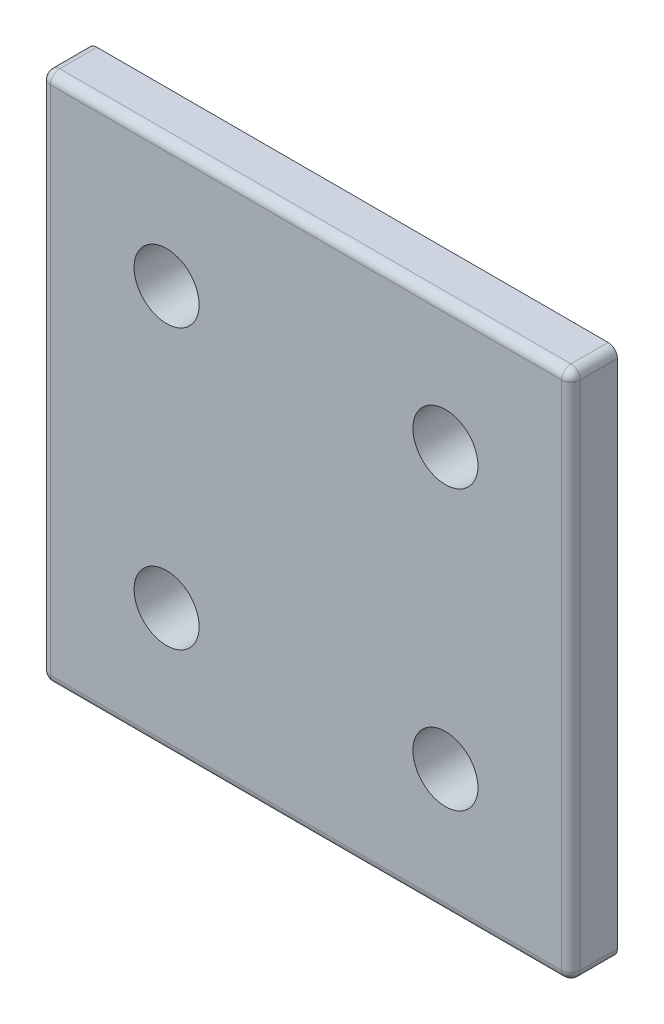
from build123d import *

# Parameters (mm, degrees)
SKETCH1_W           = 57
SKETCH1_H           = 57
SKETCH1_R           = 3.5
BOSS_EXTRUDE1_DEPTH = 2.5
FILLET1_R           = 1


with BuildPart() as part:
    # Sketch1 → Boss-Extrude1 (new body, symmetric)
    with BuildSketch(Plane.XY):
        with Locations((28.5, 28.5)):
            Rectangle(SKETCH1_W, SKETCH1_H)
        with Locations((13.5, 13.5)):
            Circle(SKETCH1_R, mode=Mode.SUBTRACT)
        with Locations((43.5, 13.5)):
            Circle(SKETCH1_R, mode=Mode.SUBTRACT)
        with Locations((13.5, 43.5)):
            Circle(SKETCH1_R, mode=Mode.SUBTRACT)
        with Locations((43.5, 43.5)):
            Circle(SKETCH1_R, mode=Mode.SUBTRACT)
    extrude(amount=BOSS_EXTRUDE1_DEPTH, both=True)

    # Fillet1
    fillet1_edges = [part.edges().sort_by_distance(p)[0] for p in [
        (28.5, 57, 2.5),
        (0, 28.5, 2.5),
        (28.5, 0, 2.5),
        (57, 28.5, 2.5),
        (0, 0, 0),
        (0, 57, 0),
        (57, 57, 0),
        (57, 0, 0),
    ]]
    fillet(fillet1_edges, radius=FILLET1_R)


solid = part.part
